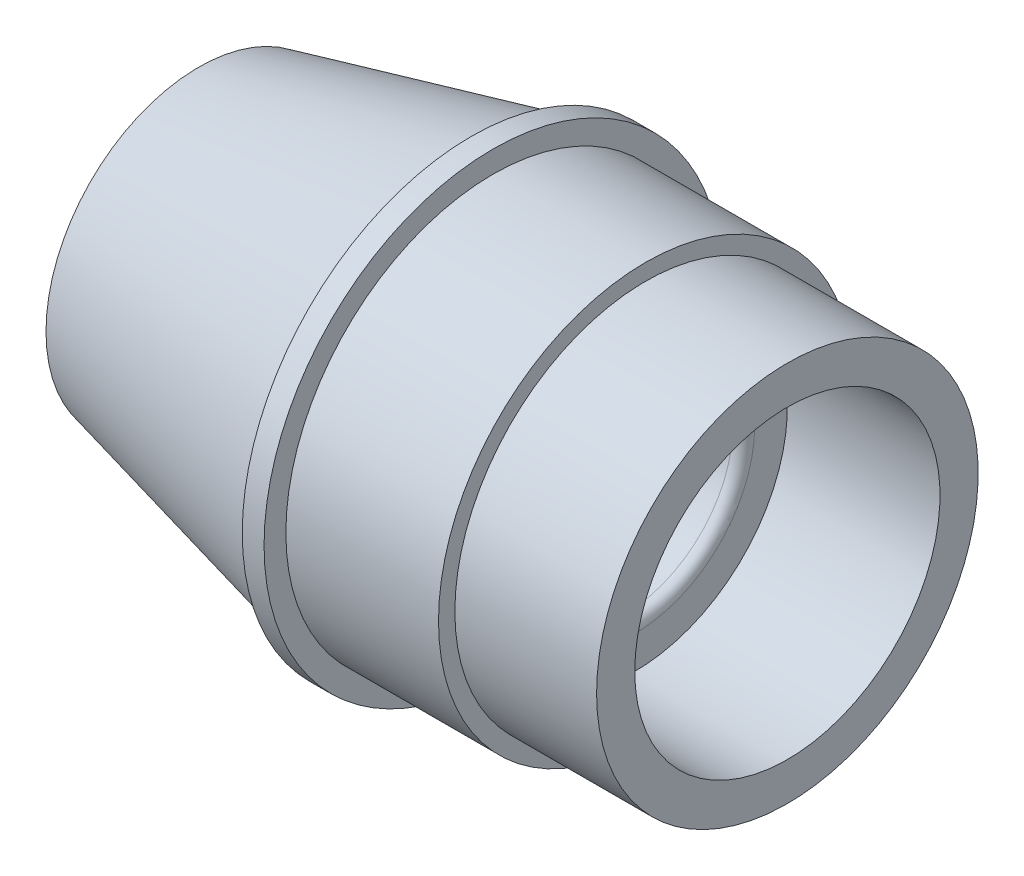
from build123d import *


with BuildPart() as part:
    # Sketch1 → Revolve1 (revolve)
    with BuildSketch(Plane.XY):
        with BuildLine():
            Line((-27, 10), (12, 10))
            ThreePointArc((12, 10), (12.707106781, 10.292893219), (13, 11))
            Line((13, 11), (13, 14))
            Line((13, 14), (27, 14))
            Line((27, 14), (27, 17.5))
            Line((27, 17.5), (14, 17.5))
            Line((14, 17.5), (14, 19))
            Line((14, 19), (0, 19))
            Line((0, 19), (0, 21))
            Line((0, 21), (-2, 21))
            Line((-2, 21), (-2, 20.229142798))
            ThreePointArc((-2, 20.229142798), (-2.062403045, 20.049198361), (-2.222815548, 19.946524269))
            Line((-2.222815548, 19.946524269), (-27, 14))
            Line((-27, 14), (-27, 10))
        make_face()
    revolve(axis=Axis((-27, 0, 0), (1, 0, 0)))


solid = part.part
